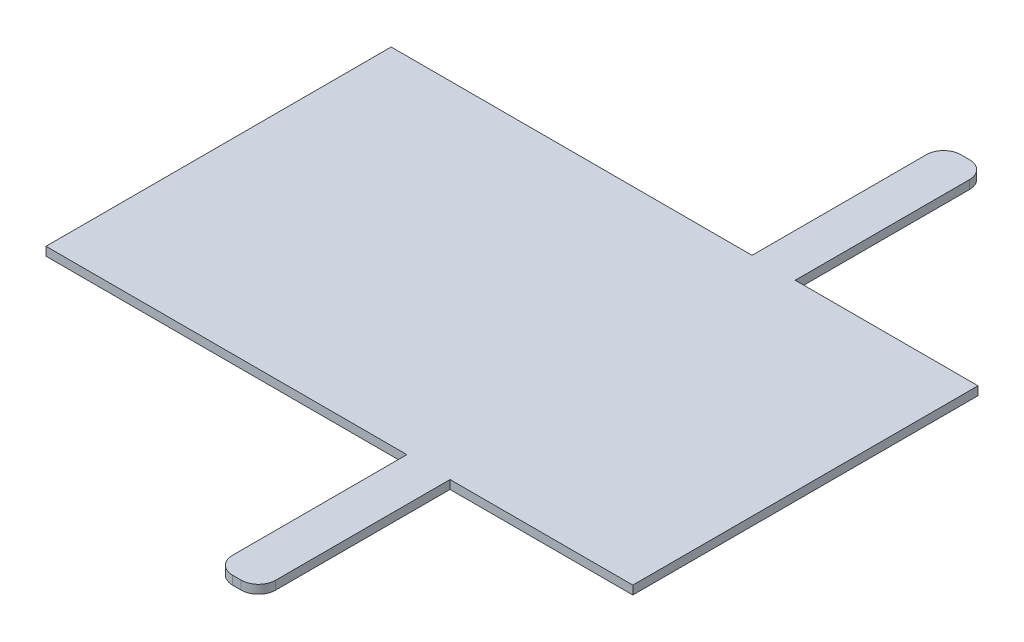
from build123d import *

# Parameters (mm, degrees)
BOSS_EXTRUDE1_DEPTH = 5


with BuildPart() as part:
    # Sketch1 → Boss-Extrude1 (new body)
    with BuildSketch(Plane(origin=(0, 0, 0), x_dir=(1, 0, 0), z_dir=(0, 1, 0))):
        with BuildLine():
            Line((-457.208642176, 422.631578947), (-351.296475424, 422.631578947))
            Line((-351.296475424, 422.631578947), (-351.296475424, 222.631578947))
            Line((-351.296475424, 222.631578947), (-457.208642176, 222.631578947))
            Line((-457.208642176, 222.631578947), (-457.208642176, 121.631578947))
            ThreePointArc((-457.208642176, 121.631578947), (-460.137574364, 114.560511136), (-467.208642176, 111.631578947))
            Line((-467.208642176, 111.631578947), (-472.208642176, 111.631578947))
            ThreePointArc((-472.208642176, 111.631578947), (-479.279709988, 114.560511136), (-482.208642176, 121.631578947))
            Line((-482.208642176, 121.631578947), (-482.208642176, 222.631578947))
            Line((-482.208642176, 222.631578947), (-691.296475424, 222.631578947))
            Line((-691.296475424, 222.631578947), (-691.296475424, 422.631578947))
            Line((-691.296475424, 422.631578947), (-482.208642176, 422.631578947))
            Line((-482.208642176, 422.631578947), (-482.208642176, 523.631578947))
            ThreePointArc((-482.208642176, 523.631578947), (-479.279709988, 530.702646759), (-472.208642176, 533.631578947))
            Line((-472.208642176, 533.631578947), (-467.208642176, 533.631578947))
            ThreePointArc((-467.208642176, 533.631578947), (-460.137574364, 530.702646759), (-457.208642176, 523.631578947))
            Line((-457.208642176, 523.631578947), (-457.208642176, 422.631578947))
        make_face()
    extrude(amount=BOSS_EXTRUDE1_DEPTH)


solid = part.part
